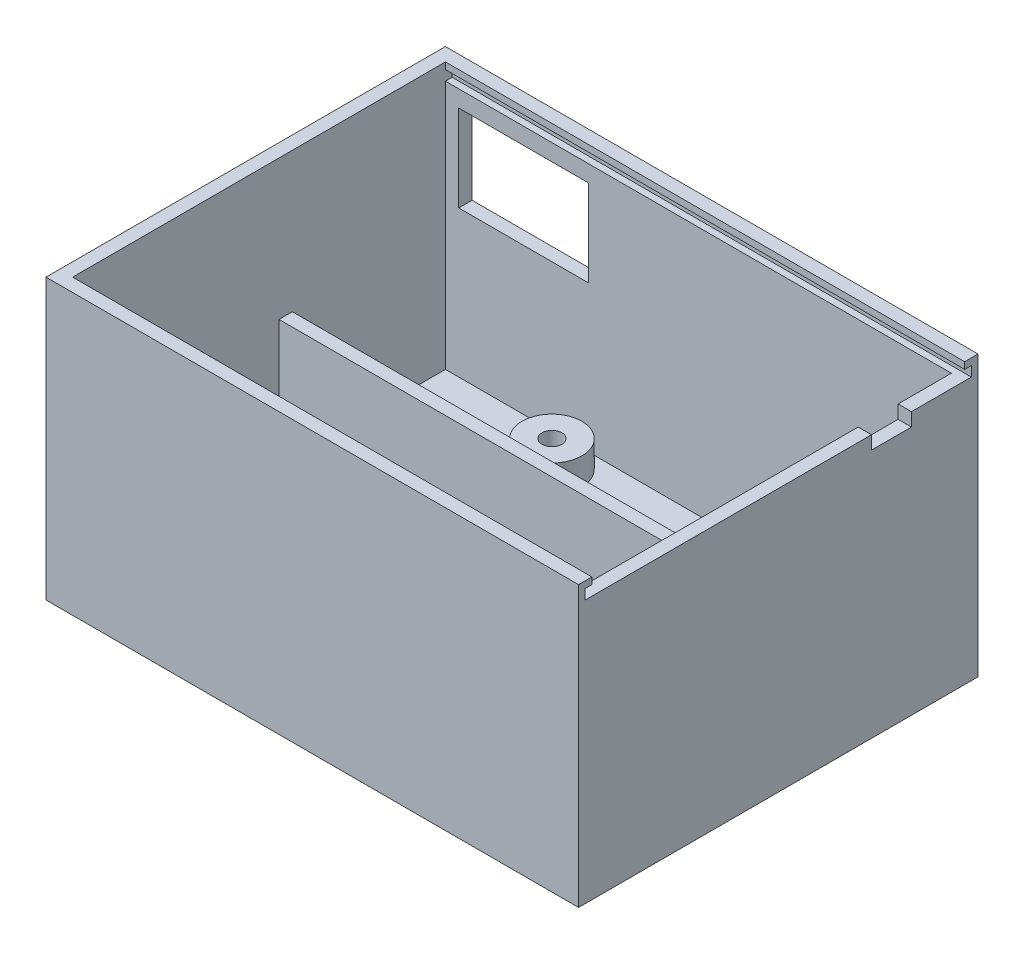
from build123d import *

# Parameters (mm, degrees)
SKIZZE1_W                       = 80
SKIZZE1_H                       = 60
AUFSATZ_LINEAR_AUSTRAGEN1_DEPTH = 42
WANDUNG1_T                      = -2
SKIZZE2_W                       = 60
SKIZZE2_H                       = 2
AUFSATZ_LINEAR_AUSTRAGEN2_DEPTH = 35
SKIZZE3_R                       = 4.5
SKIZZE3_R_2                     = 1.5
AUFSATZ_LINEAR_AUSTRAGEN3_DEPTH = 4
SKIZZE4_R                       = 4.5
SKIZZE4_R_2                     = 1.5
AUFSATZ_LINEAR_AUSTRAGEN4_DEPTH = 4
SCHNITT_LINEAR_AUSTRAGEN1_REACH = 82
SKIZZE6_W                       = 56
SKIZZE6_H                       = 2
SKIZZE7_W                       = 58
SKIZZE7_H                       = 1.5
SCHNITT_LINEAR_AUSTRAGEN2_DEPTH = 78
SCHNITT_LINEAR_AUSTRAGEN3_REACH = 82
SKIZZE8_W                       = 6
SKIZZE8_H                       = 2
SCHNITT_LINEAR_AUSTRAGEN5_REACH = 62
SKIZZE9_W                       = 19.5
SKIZZE9_H                       = 13


with BuildPart() as part:
    # Skizze1 → Aufsatz-Linear austragen1 (new body)
    with BuildSketch(Plane(origin=(0, 0, 0), x_dir=(1, 0, 0), z_dir=(0, 1, 0))):
        with Locations((40, 30)):
            Rectangle(SKIZZE1_W, SKIZZE1_H)
    extrude(amount=AUFSATZ_LINEAR_AUSTRAGEN1_DEPTH)

    # Wandung1
    wandung1_openings = [part.faces().sort_by_distance(p)[0] for p in [
        (40, 42, -30),
    ]]
    offset(amount=WANDUNG1_T, openings=wandung1_openings, kind=Kind.INTERSECTION)

    # Skizze2 → Aufsatz-Linear austragen2 (add)
    with BuildSketch(Plane(origin=(0, 2, 0), x_dir=(1, 0, 0), z_dir=(0, 1, 0))):
        with Locations((48, 18)):
            Rectangle(SKIZZE2_W, SKIZZE2_H)
    extrude(amount=AUFSATZ_LINEAR_AUSTRAGEN2_DEPTH)

    # Skizze3 → Aufsatz-Linear austragen3 (add)
    with BuildSketch(Plane(origin=(0, 2, 0), x_dir=(1, 0, 0), z_dir=(0, 1, 0))):
        with Locations((7, 24)):
            Circle(SKIZZE3_R)
        with Locations((7, 24)):
            Circle(SKIZZE3_R_2, mode=Mode.SUBTRACT)
        with Locations((23, 53)):
            Circle(SKIZZE3_R)
        with Locations((23, 53)):
            Circle(SKIZZE3_R_2, mode=Mode.SUBTRACT)
    extrude(amount=AUFSATZ_LINEAR_AUSTRAGEN3_DEPTH)

    # Skizze4 → Aufsatz-Linear austragen4 (add)
    with BuildSketch(Plane(origin=(0, 2, 0), x_dir=(1, 0, 0), z_dir=(0, 1, 0))):
        with Locations((49, 25)):
            Circle(SKIZZE4_R)
        with Locations((49, 25)):
            Circle(SKIZZE4_R_2, mode=Mode.SUBTRACT)
        with Locations((72, 48)):
            Circle(SKIZZE4_R)
        with Locations((72, 48)):
            Circle(SKIZZE4_R_2, mode=Mode.SUBTRACT)
    extrude(amount=AUFSATZ_LINEAR_AUSTRAGEN4_DEPTH)

    # Skizze6 → Schnitt-Linear austragen1 (cut, up to next)
    with BuildSketch(Plane(origin=(80, 0, 0), x_dir=(0, 0, -1), z_dir=(1, 0, 0)), mode=Mode.PRIVATE) as schnitt_linear_austragen1_sk1:
        with Locations((30, 41)):
            Rectangle(SKIZZE6_W, SKIZZE6_H)
    schnitt_linear_austragen1_tool1 = extrude(schnitt_linear_austragen1_sk1.sketch, amount=-SCHNITT_LINEAR_AUSTRAGEN1_REACH, mode=Mode.PRIVATE) & part.part
    add(schnitt_linear_austragen1_tool1.solids().sort_by_distance((80, 41, -30))[0], mode=Mode.SUBTRACT)

    # Skizze7 → Schnitt-Linear austragen2 (cut)
    with BuildSketch(Plane(origin=(80, 0, 0), x_dir=(0, 0, -1), z_dir=(1, 0, 0))):
        with Locations((30, 40.25)):
            Rectangle(SKIZZE7_W, SKIZZE7_H)
    extrude(amount=-SCHNITT_LINEAR_AUSTRAGEN2_DEPTH, mode=Mode.SUBTRACT)

    # Skizze8 → Schnitt-Linear austragen3 (cut, up to next)
    with BuildSketch(Plane(origin=(80, 0, 0), x_dir=(0, 0, -1), z_dir=(1, 0, 0)), mode=Mode.PRIVATE) as schnitt_linear_austragen3_sk1:
        with Locations((47, 38.5)):
            Rectangle(SKIZZE8_W, SKIZZE8_H)
    schnitt_linear_austragen3_tool1 = extrude(schnitt_linear_austragen3_sk1.sketch, amount=-SCHNITT_LINEAR_AUSTRAGEN3_REACH, mode=Mode.PRIVATE) & part.part
    add(schnitt_linear_austragen3_tool1.solids().sort_by_distance((80, 38.5, -47))[0], mode=Mode.SUBTRACT)

    # Skizze9 → Schnitt-Linear austragen5 (cut, up to next)
    with BuildSketch(Plane(origin=(0, 0, -60), x_dir=(-1, 0, 0), z_dir=(0, 0, -1)), mode=Mode.PRIVATE) as schnitt_linear_austragen5_sk1:
        with Locations((-13.75, 30.5)):
            Rectangle(SKIZZE9_W, SKIZZE9_H)
    schnitt_linear_austragen5_tool1 = extrude(schnitt_linear_austragen5_sk1.sketch, amount=-SCHNITT_LINEAR_AUSTRAGEN5_REACH, mode=Mode.PRIVATE) & part.part
    add(schnitt_linear_austragen5_tool1.solids().sort_by_distance((13.75, 30.5, -60))[0], mode=Mode.SUBTRACT)


solid = part.part
